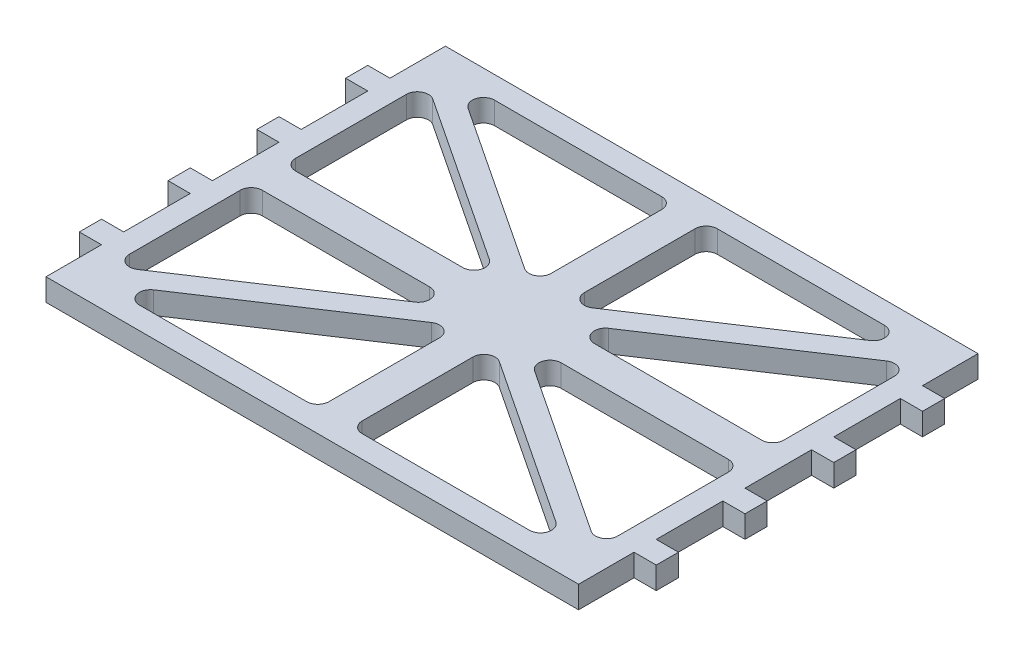
from build123d import *

# Parameters (mm, degrees)
BOSS_EXTRUDE1_DEPTH = 4
CUT_EXTRUDE1_DEPTH  = 10


with BuildPart() as part:
    # Sketch1 → Boss-Extrude1 (new body)
    with BuildSketch(Plane(origin=(0, 0, 0), x_dir=(1, 0, 0), z_dir=(0, 1, 0))):
        Polygon((-17.714285714, -48), (-17.714285714, -58), (78.285714286, -58), (78.285714286, -48), (82.285714286, -48), (82.285714286, -44), (78.285714286, -44), (78.285714286, -32), (82.285714286, -32), (82.285714286, -28), (78.285714286, -28), (78.285714286, -16), (82.285714286, -16), (82.285714286, -12), (78.285714286, -12), (78.285714286, 0), (82.285714286, 0), (82.285714286, 4), (78.285714286, 4), (78.285714286, 14), (-17.714285714, 14), (-17.714285714, 4), (-21.714285714, 4), (-21.714285714, 0), (-17.714285714, 0), (-17.714285714, -12), (-21.714285714, -12), (-21.714285714, -16), (-17.714285714, -16), (-17.714285714, -28), (-21.714285714, -28), (-21.714285714, -32), (-17.714285714, -32), (-17.714285714, -44), (-21.714285714, -44), (-21.714285714, -48), align=None)
    extrude(amount=-BOSS_EXTRUDE1_DEPTH)

    # Sketch2 → Cut-Extrude1 (cut)
    with BuildSketch(Plane(origin=(0, 0, 0), x_dir=(1, 0, 0), z_dir=(0, 1, 0))):
        with BuildLine():
            ThreePointArc((-13.714285714, 2.94278394), (-12.661123549, 4.704458744), (-10.6107876, 4.610804297))
            Line((-10.6107876, 4.610804297), (19.53422954, -15.331979643))
            ThreePointArc((19.53422954, -15.331979643), (20.345939079, -17.576176746), (18.430731426, -19))
            Line((18.430731426, -19), (-11.714285714, -19))
            ThreePointArc((-11.714285714, -19), (-13.128499277, -18.414213562), (-13.714285714, -17))
            Line((-13.714285714, -17), (-13.714285714, 2.94278394))
        make_face()
        with BuildLine():
            Line((-4.859302854, 10), (25.285714286, 10))
            ThreePointArc((25.285714286, 10), (26.699927848, 9.414213562), (27.285714286, 8))
            Line((27.285714286, 8), (27.285714286, -11.94278394))
            ThreePointArc((27.285714286, -11.94278394), (26.23255212, -13.704458744), (24.182216171, -13.610804297))
            Line((24.182216171, -13.610804297), (-5.962800969, 6.331979643))
            ThreePointArc((-5.962800969, 6.331979643), (-6.774510508, 8.576176746), (-4.859302854, 10))
        make_face()
        with BuildLine():
            Line((33.285714286, 8), (33.285714286, -11.94278394))
            ThreePointArc((33.285714286, -11.94278394), (34.338876451, -13.704458744), (36.3892124, -13.610804297))
            Line((36.3892124, -13.610804297), (66.53422954, 6.331979643))
            ThreePointArc((66.53422954, 6.331979643), (67.345939079, 8.576176746), (65.430731426, 10))
            Line((65.430731426, 10), (35.285714286, 10))
            ThreePointArc((35.285714286, 10), (33.871500723, 9.414213562), (33.285714286, 8))
        make_face()
        with BuildLine():
            ThreePointArc((74.285714286, -17), (73.699927848, -18.414213562), (72.285714286, -19))
            Line((72.285714286, -19), (42.140697146, -19))
            ThreePointArc((42.140697146, -19), (40.225489492, -17.576176746), (41.037199031, -15.331979643))
            Line((41.037199031, -15.331979643), (71.182216171, 4.610804297))
            ThreePointArc((71.182216171, 4.610804297), (73.23255212, 4.704458744), (74.285714286, 2.94278394))
            Line((74.285714286, 2.94278394), (74.285714286, -17))
        make_face()
        with BuildLine():
            ThreePointArc((74.285714286, -46.94278394), (73.23255212, -48.704458744), (71.182216171, -48.610804297))
            Line((71.182216171, -48.610804297), (41.037199031, -28.668020357))
            ThreePointArc((41.037199031, -28.668020357), (40.225489492, -26.423823254), (42.140697146, -25))
            Line((42.140697146, -25), (72.285714286, -25))
            ThreePointArc((72.285714286, -25), (73.699927848, -25.585786438), (74.285714286, -27))
            Line((74.285714286, -27), (74.285714286, -46.94278394))
        make_face()
        with BuildLine():
            Line((65.430731426, -54), (35.285714286, -54))
            ThreePointArc((35.285714286, -54), (33.871500723, -53.414213562), (33.285714286, -52))
            Line((33.285714286, -52), (33.285714286, -32.05721606))
            ThreePointArc((33.285714286, -32.05721606), (34.338876451, -30.295541256), (36.3892124, -30.389195703))
            Line((36.3892124, -30.389195703), (66.53422954, -50.331979643))
            ThreePointArc((66.53422954, -50.331979643), (67.345939079, -52.576176746), (65.430731426, -54))
        make_face()
        with BuildLine():
            Line((27.285714286, -52), (27.285714286, -32.05721606))
            ThreePointArc((27.285714286, -32.05721606), (26.23255212, -30.295541256), (24.182216171, -30.389195703))
            Line((24.182216171, -30.389195703), (-5.962800969, -50.331979643))
            ThreePointArc((-5.962800969, -50.331979643), (-6.774510508, -52.576176746), (-4.859302854, -54))
            Line((-4.859302854, -54), (25.285714286, -54))
            ThreePointArc((25.285714286, -54), (26.699927848, -53.414213562), (27.285714286, -52))
        make_face()
        with BuildLine():
            ThreePointArc((-13.714285714, -27), (-13.128499277, -25.585786438), (-11.714285714, -25))
            Line((-11.714285714, -25), (18.430731426, -25))
            ThreePointArc((18.430731426, -25), (20.345939079, -26.423823254), (19.53422954, -28.668020357))
            Line((19.53422954, -28.668020357), (-10.6107876, -48.610804297))
            ThreePointArc((-10.6107876, -48.610804297), (-12.661123549, -48.704458744), (-13.714285714, -46.94278394))
            Line((-13.714285714, -46.94278394), (-13.714285714, -27))
        make_face()
    extrude(amount=-CUT_EXTRUDE1_DEPTH, mode=Mode.SUBTRACT)


solid = part.part
